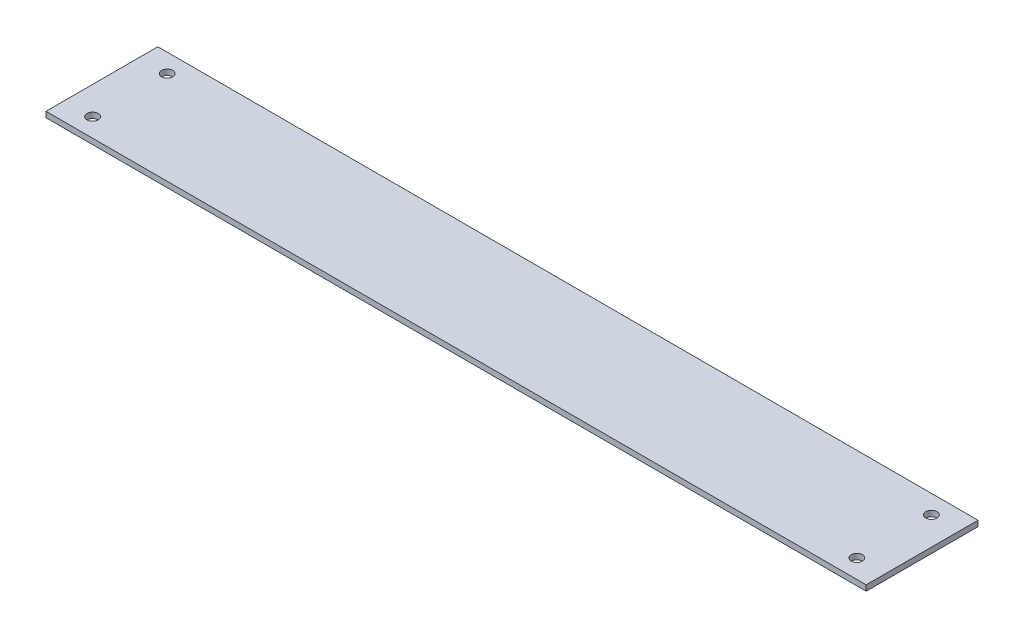
from build123d import *

# Parameters (mm, degrees)
SKETCH1_W           = 220
SKETCH1_H           = 30
SKETCH1_R           = 1.5
BOSS_EXTRUDE1_DEPTH = 1.5


with BuildPart() as part:
    # Sketch1 → Boss-Extrude1 (new body)
    with BuildSketch(Plane(origin=(0, 0, 0), x_dir=(1, 0, 0), z_dir=(0, 1, 0))):
        Rectangle(SKETCH1_W, SKETCH1_H)
        with Locations((-102.5, 10)):
            Circle(SKETCH1_R, mode=Mode.SUBTRACT)
        with Locations((-102.5, -10)):
            Circle(SKETCH1_R, mode=Mode.SUBTRACT)
        with Locations((102.5, 10)):
            Circle(SKETCH1_R, mode=Mode.SUBTRACT)
        with Locations((102.5, -10)):
            Circle(SKETCH1_R, mode=Mode.SUBTRACT)
    extrude(amount=BOSS_EXTRUDE1_DEPTH)


solid = part.part
